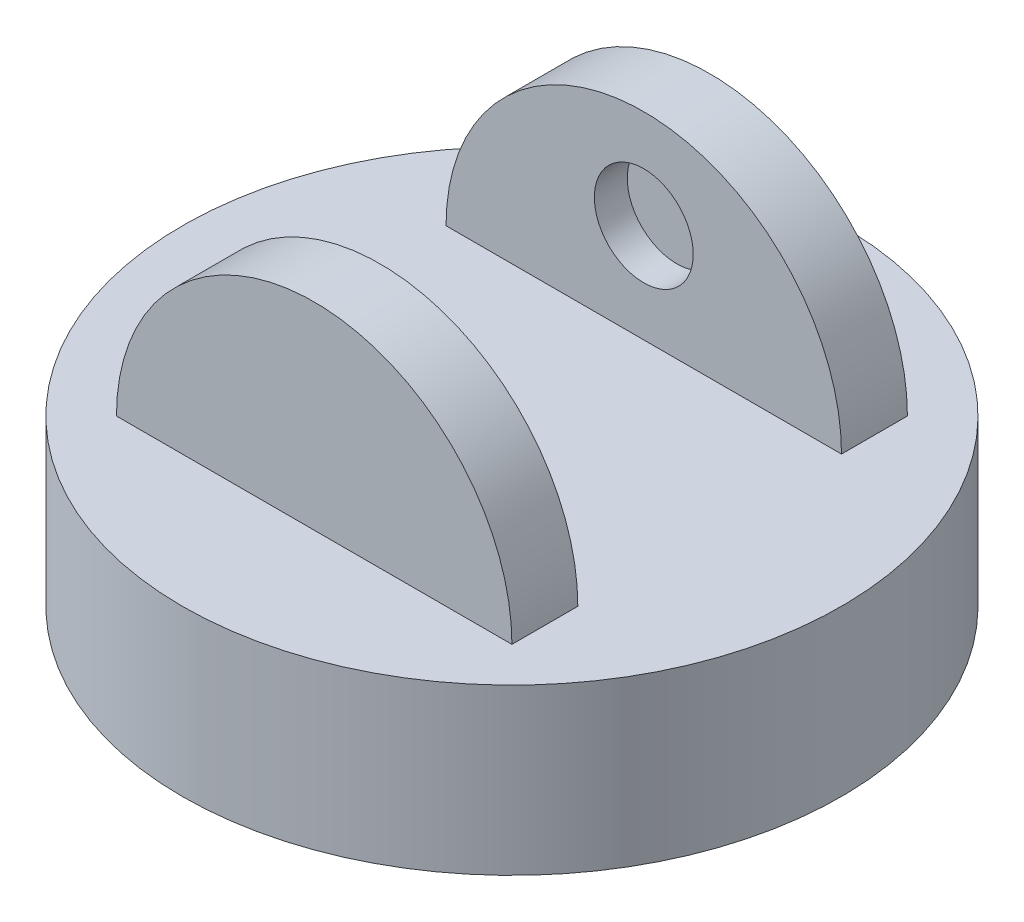
from build123d import *

# Parameters (mm, degrees)
SKETCH1_R           = 100
BOSS_EXTRUDE1_DEPTH = 50
BOSS_EXTRUDE2_DEPTH = 60
BOSS_EXTRUDE4_DEPTH = 60
SKETCH9_W           = 120
SKETCH9_H           = 80
CUT_EXTRUDE1_DEPTH  = 68
SKETCH15_R          = 15
CUT_EXTRUDE3_DEPTH  = 10
SKETCH19_R          = 15
CUT_EXTRUDE4_DEPTH  = 10


with BuildPart() as part:
    # Sketch1 → Boss-Extrude1 (new body)
    with BuildSketch(Plane(origin=(0, 0, 0), x_dir=(1, 0, 0), z_dir=(0, 1, 0))):
        Circle(SKETCH1_R)
    extrude(amount=BOSS_EXTRUDE1_DEPTH)

    # Sketch2 → Boss-Extrude2 (add)
    with BuildSketch(Plane.XY):
        with BuildLine():
            Line((-60, 50), (0, 50))
            Line((0, 50), (60, 50))
            ThreePointArc((60, 50), (0, 110), (-60, 50))
        make_face()
    extrude(amount=BOSS_EXTRUDE2_DEPTH)

    # Sketch6 → Boss-Extrude4 (add)
    with BuildSketch(Plane(origin=(0, 0, 0), x_dir=(-1, 0, 0), z_dir=(0, 0, -1))):
        with BuildLine():
            Line((-60, 50), (60, 50))
            ThreePointArc((60, 50), (0, 110), (-60, 50))
        make_face()
    extrude(amount=BOSS_EXTRUDE4_DEPTH)

    # Sketch9 → Cut-Extrude1 (cut)
    with BuildSketch(Plane(origin=(0, 50, 0), x_dir=(1, 0, 0), z_dir=(0, 1, 0))):
        Rectangle(SKETCH9_W, SKETCH9_H)
    extrude(amount=CUT_EXTRUDE1_DEPTH, mode=Mode.SUBTRACT)

    # Sketch15 → Cut-Extrude3 (cut)
    with BuildSketch(Plane(origin=(0, 0, 40), x_dir=(-1, 0, 0), z_dir=(0, 0, -1))):
        with Locations((0, 80)):
            Circle(SKETCH15_R)
    extrude(amount=-CUT_EXTRUDE3_DEPTH, mode=Mode.SUBTRACT)

    # Sketch19 → Cut-Extrude4 (cut)
    with BuildSketch(Plane.XY.offset(-40)):
        with Locations((0, 80)):
            Circle(SKETCH19_R)
    extrude(amount=-CUT_EXTRUDE4_DEPTH, mode=Mode.SUBTRACT)


solid = part.part
